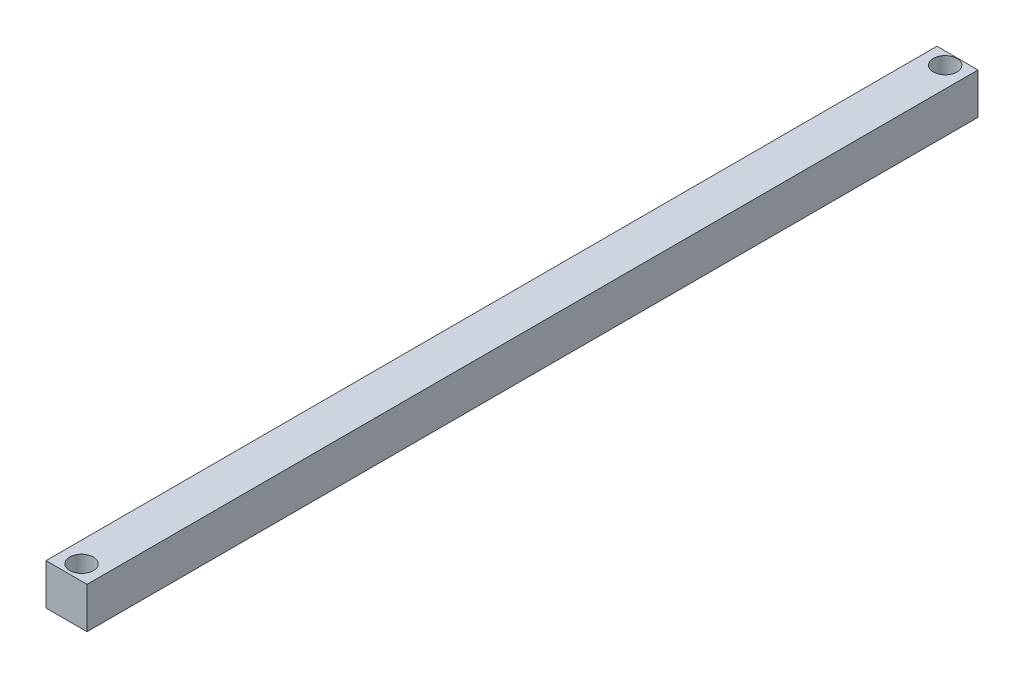
from build123d import *

# Parameters (mm, degrees)
SKETCH1_W           = 20
SKETCH1_H           = 434
BOSS_EXTRUDE1_DEPTH = 20
SKETCH3_R           = 5.75
CUT_EXTRUDE1_DEPTH  = 21


with BuildPart() as part:
    # Sketch1 → Boss-Extrude1 (new body)
    with BuildSketch(Plane(origin=(0, 0, 0), x_dir=(1, 0, 0), z_dir=(0, 1, 0))):
        Rectangle(SKETCH1_W, SKETCH1_H)
    extrude(amount=BOSS_EXTRUDE1_DEPTH)

    # Sketch3 → Cut-Extrude1 (cut, through all)
    with BuildSketch(Plane(origin=(0, 20, 0), x_dir=(1, 0, 0), z_dir=(0, 1, 0))):
        with Locations((0, 211)):
            Circle(SKETCH3_R)
        with Locations((0, -209.68)):
            Circle(SKETCH3_R)
    extrude(amount=-CUT_EXTRUDE1_DEPTH, mode=Mode.SUBTRACT)


solid = part.part
